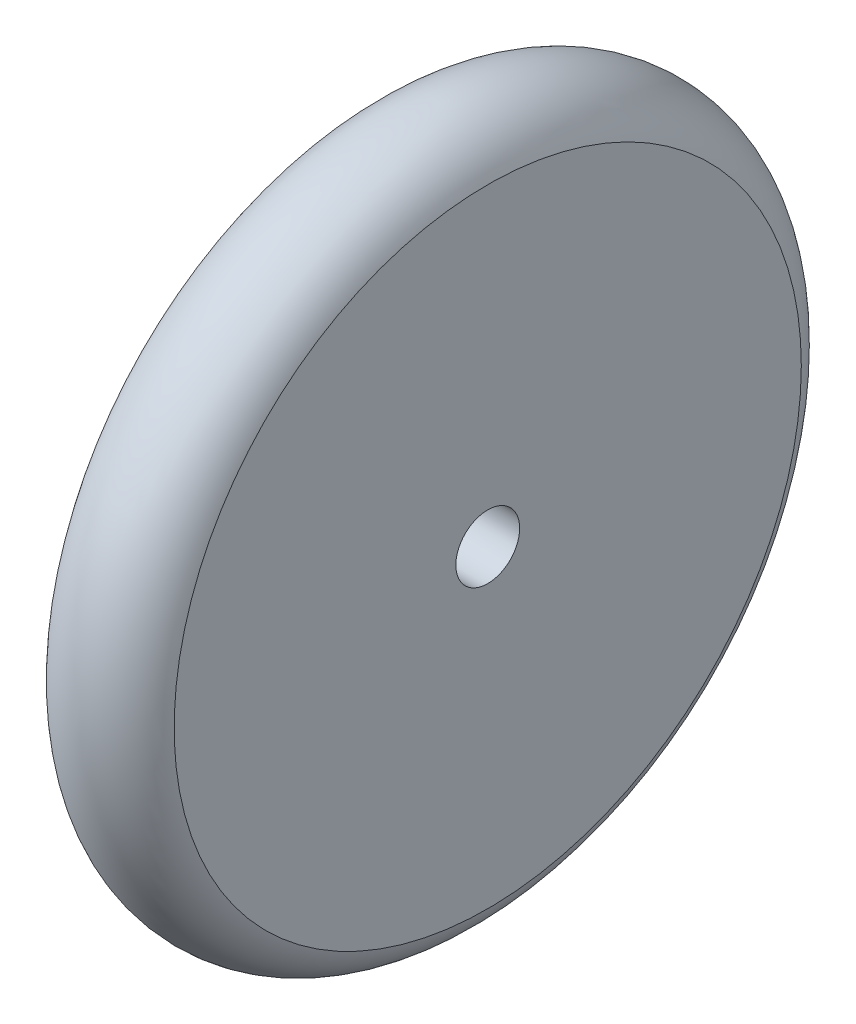
from build123d import *


with BuildPart() as part:
    # Esquisse2 → Révolution1 (revolve)
    with BuildSketch(Plane.XY):
        with BuildLine():
            Line((-7.5, 4), (-7.5, 39.290584114))
            ThreePointArc((-7.5, 39.290584114), (0, 44.488732048), (7.5, 39.290584114))
            Line((7.5, 39.290584114), (7.5, 4))
            Line((7.5, 4), (-7.5, 4))
        make_face()
    revolve(axis=Axis((0, 0, 0), (-1, 0, 0)))


solid = part.part
